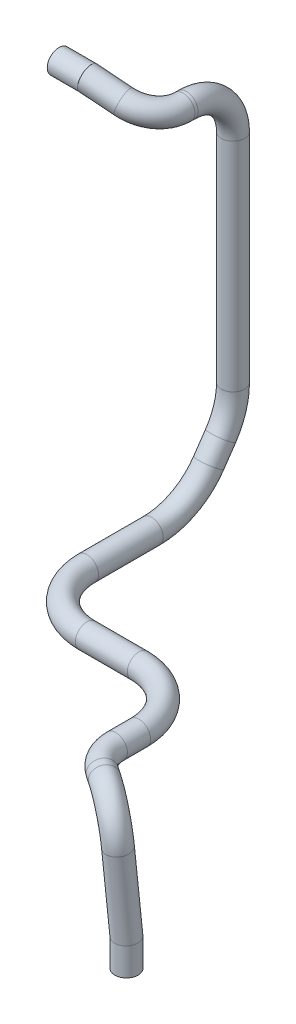
from build123d import *

# Parameters (mm, degrees)
WYCI_GNI_CIE_PO_CIE_CE_CIENKA_CIAN_2_R   = 10
WYCI_GNI_CIE_PO_CIE_CE_CIENKA_CIAN_2_R_2 = 7.5


with BuildPart() as part:
    # Wyci_gni_cie po _cie_ce-Cienka _cianka1: sweep along a curve in space
    with BuildLine() as wyci_gni_cie_po_cie_ce_cienka_cianka1_path:
        Line((1044.71, 559.076994309, 249.044106753), (1069.71, 559.076994309, 249.044106753))
        Line((1069.71, 559.076994309, 249.044106753), (1094.247528015, 550.768418853, 243.042459439))
        ThreePointArc((1116.249651475, 543.318348786, 213.816501266), (1110.079141966, 545.407725672, 232.483006106), (1094.247528015, 550.768418853, 243.042459439))
        Line((1116.249651475, 543.318348786, 213.816501266), (1116.249651475, 543.318348786, 211.109143016))
        ThreePointArc((1116.249651475, 543.318348786, 211.109143016), (1116.249651475, 531.602620034, 182.824871768), (1116.249651475, 503.318348786, 171.109143016))
        Line((1116.249651475, 503.318348786, 171.109143016), (1116.249651475, 316.877757738, 171.109143016))
        ThreePointArc((1116.249651475, 316.877757738, 171.109143016), (1116.277480624, 298.954721694, 173.848502371), (1116.358426807, 282.668357982, 181.816431207))
        Line((1116.358426807, 282.668357982, 181.816431207), (1116.463233846, 267.802351295, 192.133100875))
        ThreePointArc((1116.463233846, 267.802351295, 192.133100875), (1116.596863, 248.848167314, 213.609746287), (1116.645068439, 242.010626862, 241.426485169))
        Line((1116.645068439, 242.010626862, 241.426485169), (1116.645068439, 242.010626862, 296.867195517))
        ThreePointArc((1116.645068439, 242.010626862, 296.867195517), (1131.289729379, 242.010626862, 332.222534576), (1166.645068439, 242.010626862, 346.867195517))
        Line((1166.645068439, 242.010626862, 346.867195517), (1211.274131128, 242.010626862, 346.867195517))
        ThreePointArc((1211.274131128, 242.010626862, 346.867195517), (1246.629470187, 242.010626862, 361.511856457), (1261.274131128, 242.010626862, 396.867195517))
        Line((1261.274131128, 242.010626862, 396.867195517), (1261.274131128, 242.010626862, 416.778975796))
        ThreePointArc((1261.274131128, 242.010626862, 416.778975796), (1264.794797868, 242.005067906, 430.88022193), (1274.530457438, 241.989695787, 441.67174472))
        Line((1274.530457438, 241.989695787, 441.67174472), (1280.423804228, 241.980390487, 445.635799564))
        ThreePointArc((1280.423804228, 241.980390487, 445.635799564), (1298.647190265, 232.928434323, 457.002940429), (1306.67607752, 211.292618973, 460.269446831))
        Line((1306.67607752, 211.292618973, 460.269446831), (1308.299251629, 142.99, 454.620731707))
        Line((1308.299251629, 118.99, 454.620731707), (1308.299251629, 142.99, 454.620731707))
    # Wyci_gni_cie po _cie_ce-Cienka _cian 2 (on start of the path) → Wyci_gni_cie po _cie_ce-Cienka _cianka1 (sweep)
    with BuildSketch(Plane(origin=(1044.71, 559.076994309, 249.044106753), x_dir=(0, 0, 1), z_dir=(1, 0, 0))):
        Circle(WYCI_GNI_CIE_PO_CIE_CE_CIENKA_CIAN_2_R)
        Circle(WYCI_GNI_CIE_PO_CIE_CE_CIENKA_CIAN_2_R_2, mode=Mode.SUBTRACT)
    sweep(path=wyci_gni_cie_po_cie_ce_cienka_cianka1_path.line, transition=Transition.RIGHT)


solid = part.part
